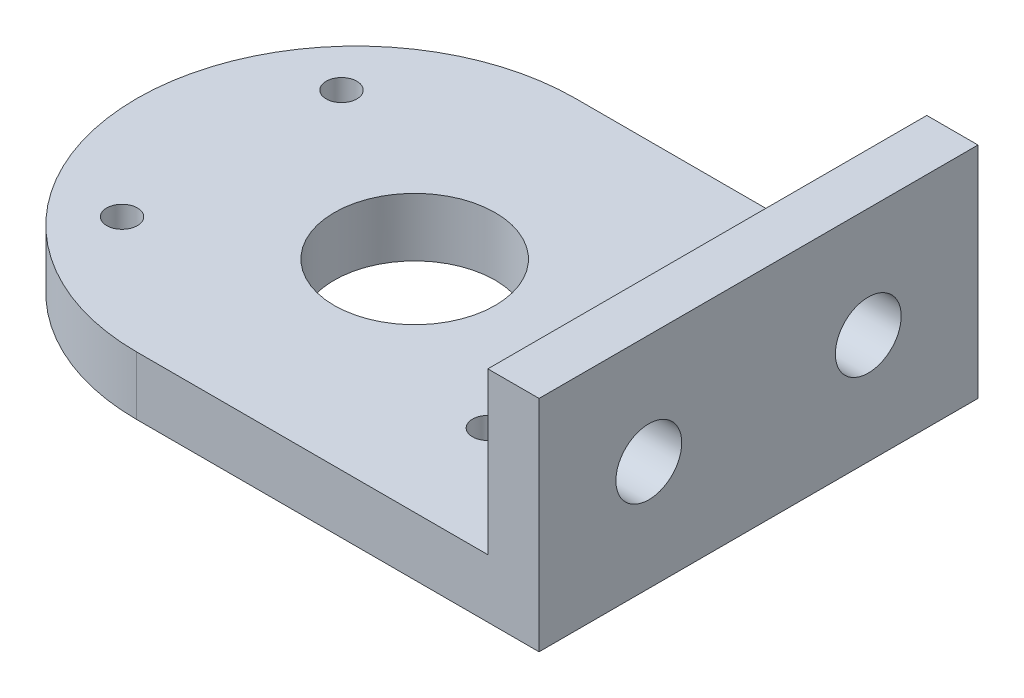
from build123d import *

# Parameters (mm, degrees)
EXTRUDE_1_DEPTH     = 8
SKETCH_2_W          = 7
SKETCH_2_H          = 60
EXTRUDE_2_DEPTH     = 22
MM_1_D              = 9
HOLE_WIZARD_M5_1_D  = 4.2
SKETCH_5_R          = 11
CUT_EXTRUDE_1_DEPTH = 10


with BuildPart() as part:
    # 草图1 → 凸台-拉伸1 (new body)
    with BuildSketch(Plane(origin=(0, 0, 0), x_dir=(1, 0, 0), z_dir=(0, 1, 0))):
        with BuildLine():
            Line((-14.75, 30), (40.25, 30))
            Line((40.25, 30), (40.25, -30))
            Line((40.25, -30), (-14.75, -30))
            ThreePointArc((-14.75, -30), (-44.75, 0), (-14.75, 30))
        make_face()
    extrude(amount=EXTRUDE_1_DEPTH)

    # 草图2 → 凸台-拉伸2 (add)
    with BuildSketch(Plane(origin=(0, 8, 0), x_dir=(1, 0, 0), z_dir=(0, 1, 0))):
        with Locations((36.75, 0)):
            Rectangle(SKETCH_2_W, SKETCH_2_H)
    extrude(amount=EXTRUDE_2_DEPTH)

    # 大小mm 暗销孔1 (through all)
    with Locations(Plane(origin=(40.25, 15, 15), x_dir=(0, 0, 1), z_dir=(1, 0, 0))):
        with Locations((0, 0), (-30, 0)):
            Hole(MM_1_D / 2)

    # M5 螺纹孔1 (through all)
    with Locations(Plane(origin=(-31.75, 0, 15), x_dir=(0, 0, -1), z_dir=(0, -1, 0))):
        with Locations((0, 0), (0, 50), (30, 50), (30, 0)):
            Hole(HOLE_WIZARD_M5_1_D / 2)

    # 草图5 → 切除-拉伸1 (cut)
    with BuildSketch(Plane.XZ):
        with Locations((-6.75, 0)):
            Circle(SKETCH_5_R)
    extrude(amount=-CUT_EXTRUDE_1_DEPTH, mode=Mode.SUBTRACT)


solid = part.part
